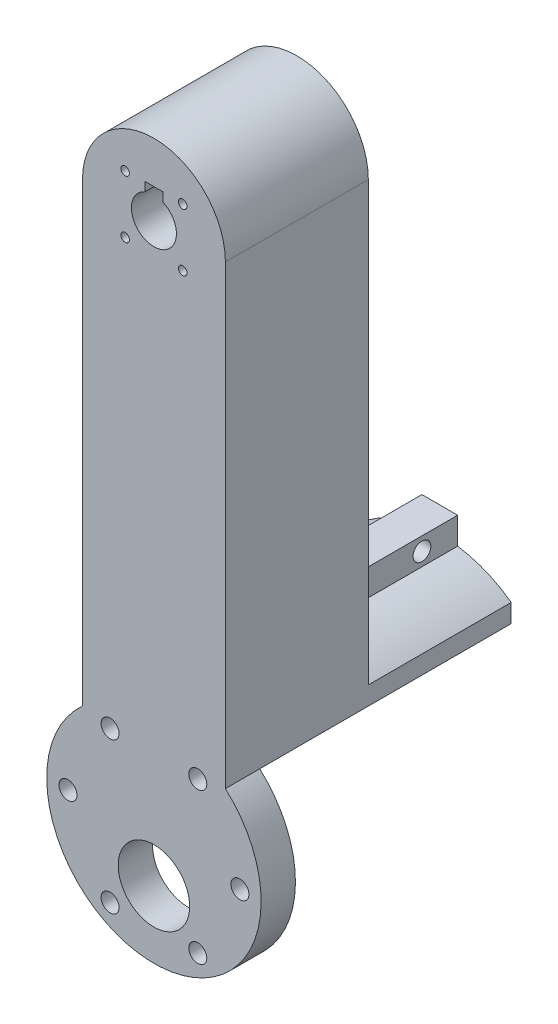
from build123d import *

# Parameters (mm, degrees)
SKETCH1_R           = 4
SKETCH1_R_2         = 0.762
BOSS_EXTRUDE1_DEPTH = 25.4
SKETCH2_R           = 19.05
BOSS_EXTRUDE2_DEPTH = 25.4
SKETCH5_R           = 6.35
CUT_EXTRUDE2_DEPTH  = 25.4
SKETCH3_R           = 1.6
CUT_EXTRUDE1_DEPTH  = 25.4
SKETCH6_W           = 3.175
SKETCH6_H           = 1.5875
CUT_EXTRUDE3_DEPTH  = 25.4
SKETCH8_R           = 19.05
CUT_EXTRUDE4_DEPTH  = 19.3
BOSS_EXTRUDE3_DEPTH = 25.4
SKETCH10_W          = 6.35
SKETCH10_H          = 4.7625
BOSS_EXTRUDE4_DEPTH = 25.4
SKETCH11_R          = 1.5875
CUT_EXTRUDE5_DEPTH  = 23.225


with BuildPart() as part:
    # Sketch1 → Boss-Extrude1 (new body)
    with BuildSketch(Plane.XY):
        with BuildLine():
            Line((12.7, 50.8), (12.7, -50.8))
            ThreePointArc((12.7, -50.8), (0, -63.5), (-12.7, -50.8))
            Line((-12.7, -50.8), (-12.7, 50.8))
            ThreePointArc((-12.7, 50.8), (0, 63.5), (12.7, 50.8))
        make_face()
        with Locations((0, 50.8)):
            Circle(SKETCH1_R, mode=Mode.SUBTRACT)
        with Locations((-5.118745989, 55.918745989)):
            Circle(SKETCH1_R_2, mode=Mode.SUBTRACT)
        with Locations((5.118745989, 55.918745989)):
            Circle(SKETCH1_R_2, mode=Mode.SUBTRACT)
        with Locations((5.118745989, 45.681254011)):
            Circle(SKETCH1_R_2, mode=Mode.SUBTRACT)
        with Locations((-5.118745989, 45.681254011)):
            Circle(SKETCH1_R_2, mode=Mode.SUBTRACT)
    extrude(amount=BOSS_EXTRUDE1_DEPTH)

    # Sketch2 → Boss-Extrude2 (add)
    with BuildSketch(Plane(origin=(0, 0, 0), x_dir=(-1, 0, 0), z_dir=(0, 0, -1))):
        with Locations((0, -44.45)):
            Circle(SKETCH2_R)
    extrude(amount=-BOSS_EXTRUDE2_DEPTH)

    # Sketch5 → Cut-Extrude2 (cut)
    with BuildSketch(Plane.XY.offset(25.4)):
        with Locations((0, -51.562)):
            Circle(SKETCH5_R)
    extrude(amount=-CUT_EXTRUDE2_DEPTH, mode=Mode.SUBTRACT)

    # Sketch3 → Cut-Extrude1 (cut)
    with BuildSketch(Plane.XY.offset(25.4)):
        with Locations((-7.794229315, -31.235903463)):
            Circle(SKETCH3_R)
        with Locations((-15.2766, -44.45)):
            Circle(SKETCH3_R)
        with Locations((15.2766, -44.45)):
            Circle(SKETCH3_R)
        with Locations((-7.794229315, -58.017540858)):
            Circle(SKETCH3_R)
        with Locations((7.794229315, -31.235903463)):
            Circle(SKETCH3_R)
        with Locations((7.794229315, -58.017540858)):
            Circle(SKETCH3_R)
    extrude(amount=-CUT_EXTRUDE1_DEPTH, mode=Mode.SUBTRACT)

    # Sketch6 → Cut-Extrude3 (cut)
    with BuildSketch(Plane(origin=(0, 0, 0), x_dir=(-1, 0, 0), z_dir=(0, 0, -1))):
        with Locations((0, 55.265240671)):
            Rectangle(SKETCH6_W, SKETCH6_H)
    extrude(amount=-CUT_EXTRUDE3_DEPTH, mode=Mode.SUBTRACT)

    # Sketch8 → Cut-Extrude4 (cut)
    with BuildSketch(Plane(origin=(0, 0, 0), x_dir=(-1, 0, 0), z_dir=(0, 0, -1))):
        with Locations((0, -44.45)):
            Circle(SKETCH8_R)
    extrude(amount=-CUT_EXTRUDE4_DEPTH, mode=Mode.SUBTRACT)

    # Sketch9 → Boss-Extrude3 (add)
    with BuildSketch(Plane(origin=(0, 0, 0), x_dir=(-1, 0, 0), z_dir=(0, 0, -1))):
        with BuildLine():
            Line((-12.7, -30.250968343), (-12.7, -26.990386602))
            ThreePointArc((-12.7, -26.990386602), (0, -22.86), (12.7, -26.990386602))
            Line((12.7, -26.990386602), (12.7, -30.250968343))
            ThreePointArc((12.7, -30.250968343), (0, -25.4), (-12.7, -30.250968343))
        make_face()
    extrude(amount=BOSS_EXTRUDE3_DEPTH)

    # Sketch10 → Boss-Extrude4 (add)
    with BuildSketch(Plane(origin=(0, 0, 0), x_dir=(-1, 0, 0), z_dir=(0, 0, -1))):
        with Locations((0, -20.713481915)):
            Rectangle(SKETCH10_W, SKETCH10_H)
    extrude(amount=BOSS_EXTRUDE4_DEPTH)

    # Sketch11 → Cut-Extrude5 (cut, through all)
    with BuildSketch(Plane(origin=(3.175, 0, 0), x_dir=(0, 0, -1), z_dir=(1, 0, 0))):
        with Locations((6.35, -20.713481915)):
            Circle(SKETCH11_R)
        with Locations((19.05, -20.713481915)):
            Circle(SKETCH11_R)
    extrude(amount=-CUT_EXTRUDE5_DEPTH, mode=Mode.SUBTRACT)


solid = part.part
